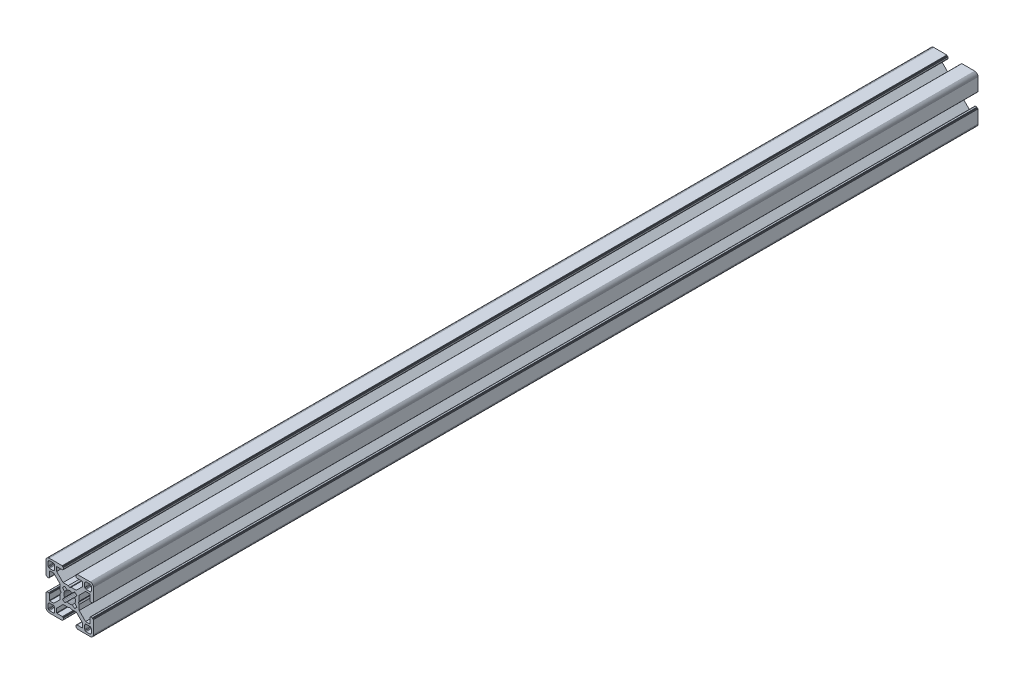
from build123d import *

# Parameters (mm, degrees)
BOSS_EXTRUDE1_DEPTH = 560


with BuildPart() as part:
    # Sketch1 → Boss-Extrude1 (new body)
    with BuildSketch(Plane.XY):
        Polygon((28.34729664, 29.969613999), (28.000000864, 29.999999329), (19.750000909, 29.999999329), (19.715268165, 29.996961355), (19.681595266, 29.987938702), (19.649999216, 29.973205179), (19.621443003, 29.953207821), (19.596790895, 29.928557575), (19.576793537, 29.899999499), (19.562061876, 29.868405312), (19.55303736, 29.834728688), (19.549999386, 29.799999669), (19.549999386, 29.699999839), (19.546961412, 29.665268958), (19.537936896, 29.631596059), (19.523203373, 29.599998146), (19.503207877, 29.571441934), (19.478557631, 29.546789825), (19.449999556, 29.526794329), (19.418403506, 29.512060806), (19.384728745, 29.503038153), (19.349999726, 29.500000179), (19.249999896, 29.500000179), (19.215267517, 29.496958527), (19.181592755, 29.487935874), (19.149996706, 29.47320235), (19.12143863, 29.453206855), (19.096788384, 29.428554746), (19.076791026, 29.399996671), (19.062057503, 29.368402484), (19.05303485, 29.334725859), (19.049996876, 29.299998703), (19.049996876, 28.39999837), (19.059110798, 28.29580945), (19.08618062, 28.194785165), (19.13038119, 28.099997016), (19.190369539, 28.014324653), (19.264324002, 27.94037019), (19.349996366, 27.88038184), (19.444784515, 27.836181271), (19.545806937, 27.809111449), (19.650010894, 27.799984574), (23.050010706, 27.799984574), (23.084741588, 27.7969466), (23.118414487, 27.787923946), (23.150012399, 27.773190423), (23.178568612, 27.753193065), (23.203220721, 27.728542819), (23.223218079, 27.699984744), (23.237949739, 27.668386831), (23.246974255, 27.634713932), (23.25001142, 27.59998608), (23.25001142, 25.049987618), (19.204474482, 20.999982084), (15.900007876, 20.999982084), (15.000008474, 20.48483404), (14.10000814, 20.999982084), (10.795543398, 20.999982084), (7.997342887, 23.801274731), (6.750011387, 25.049984589), (6.750011387, 27.599983051), (6.753049362, 27.634713932), (6.762072946, 27.668386831), (6.776805538, 27.699984744), (6.796801965, 27.728542819), (6.821454073, 27.753193065), (6.850011218, 27.773190423), (6.881607267, 27.787923946), (6.915282029, 27.7969466), (6.950011048, 27.799984574), (10.350011791, 27.799984574), (10.45420071, 27.809098497), (10.555223133, 27.836168318), (10.650011282, 27.880368888), (10.735683645, 27.940357238), (10.809638108, 28.014311701), (10.869626458, 28.099984064), (10.913827027, 28.194772213), (10.940895918, 28.295796498), (10.950010772, 28.399985417), (10.950010772, 29.299985751), (10.946974575, 29.334739239), (10.93795065, 29.368415522), (10.923215933, 29.400009153), (10.903218427, 29.428566473), (10.878566319, 29.45321765), (10.849999264, 29.473204166), (10.818403214, 29.487937689), (10.784728453, 29.496960342), (10.749999434, 29.500000179), (10.649999604, 29.500000179), (10.615270585, 29.503038153), (10.581595823, 29.512060806), (10.549999774, 29.526794329), (10.521441698, 29.546789825), (10.496791452, 29.571441934), (10.476795025, 29.599998146), (10.462061502, 29.631596059), (10.453037918, 29.665268958), (10.449999943, 29.699999839), (10.449999943, 29.799999669), (10.446961969, 29.834728688), (10.437938385, 29.868405312), (10.423205793, 29.899999499), (10.403208435, 29.928557575), (10.378557257, 29.953207821), (10.350000113, 29.973205179), (10.318404064, 29.987938702), (10.284729302, 29.996961355), (10.250000283, 29.999999329), (1.999999397, 29.999999329), (1.652702689, 29.969613999), (1.315958682, 29.879383743), (0.999999233, 29.732050374), (0.714424066, 29.532089829), (0.467910431, 29.285576195), (0.267948955, 28.999999166), (0.120614655, 28.684040532), (0.030384399, 28.34729664), (0, 28.000000864), (0, 19.750000909), (0.003037974, 19.715268165), (0.012061559, 19.681595266), (0.026795082, 19.649999216), (0.046790577, 19.621441141), (0.071442686, 19.596789032), (0.09999983, 19.576793537), (0.13159588, 19.562060013), (0.165270641, 19.55303736), (0.19999966, 19.549999386), (0.299999461, 19.549999386), (0.334728509, 19.546959549), (0.368403242, 19.537936896), (0.399999321, 19.523203373), (0.428556465, 19.503207877), (0.453208573, 19.478555769), (0.473204069, 19.449997693), (0.487937592, 19.418403506), (0.496961176, 19.384728745), (0.499999151, 19.349999726), (0.499999151, 19.249998033), (0.503038056, 19.215269014), (0.512060709, 19.181594253), (0.526794232, 19.150000066), (0.546790194, 19.121441524), (0.571441837, 19.096789882), (0.60000029, 19.076794925), (0.631595686, 19.062061999), (0.665270619, 19.053039982), (0.700000626, 19.050000801), (1.60000096, 19.050000801), (1.704189879, 19.059116587), (1.805213233, 19.086186409), (1.90000045, 19.130385115), (1.985673745, 19.190375328), (2.059627277, 19.264327928), (2.119616325, 19.350002154), (2.163816196, 19.444788441), (2.190886018, 19.545812726), (2.200000872, 19.650001645), (2.200000872, 23.050001457), (2.203039777, 23.084732338), (2.212062431, 23.118405237), (2.226795954, 23.15000315), (2.246792381, 23.178559362), (2.271443558, 23.203211471), (2.300000702, 23.223206967), (2.331596752, 23.23794049), (2.365271513, 23.246965006), (2.400001464, 23.250001117), (4.950000857, 23.250001117), (7.997332093, 20.202670812), (8.995535423, 19.204467788), (8.995535423, 15.900001182), (9.515148227, 15.00000178), (8.995535423, 14.100002378), (8.995535423, 10.795536704), (4.950000857, 6.750002138), (2.400001464, 6.750002138), (2.365271513, 6.753040112), (2.331596752, 6.762063697), (2.300000702, 6.77679722), (2.271443558, 6.796793647), (2.246792381, 6.821444824), (2.226795954, 6.850001968), (2.212062431, 6.881598018), (2.203039777, 6.915272779), (2.200000872, 6.950002729), (2.200000872, 10.350002542), (2.190896812, 10.454174265), (2.16382699, 10.555197618), (2.119627119, 10.649984836), (2.059638071, 10.735658131), (1.985684539, 10.809611663), (1.900011244, 10.869600944), (1.805224027, 10.913800582), (1.704200673, 10.940870404), (1.600011754, 10.949986189), (0.70001142, 10.949986189), (0.665281355, 10.946948596), (0.631606253, 10.937926283), (0.600010578, 10.923193954), (0.571451747, 10.903199537), (0.546799638, 10.87854836), (0.526794232, 10.850000195), (0.512060709, 10.818404146), (0.503038056, 10.784730315), (0.499999151, 10.750000365), (0.499999151, 10.650000535), (0.496961176, 10.615270585), (0.487937592, 10.581596754), (0.473204069, 10.550000705), (0.453208573, 10.521443561), (0.428556465, 10.496791452), (0.399999321, 10.476795956), (0.368403242, 10.462062433), (0.334728509, 10.453038849), (0.299999461, 10.449999943), (0.19999966, 10.449999943), (0.165270641, 10.446961969), (0.13159588, 10.437939316), (0.09999983, 10.423205793), (0.071442686, 10.403209366), (0.046790577, 10.378558189), (0.026795082, 10.350000113), (0.012061559, 10.318404064), (0.003037974, 10.284729302), (0, 10.250000283), (0, 1.999999397), (0.030384399, 1.652702689), (0.120614655, 1.315958682), (0.267948955, 0.999999233), (0.467910431, 0.714424066), (0.714424066, 0.467910431), (0.999999233, 0.267948955), (1.315958682, 0.120614655), (1.652702689, 0.030384399), (1.999999397, 0), (10.250000283, 0), (10.284729302, 0.003037974), (10.318404064, 0.012061559), (10.350000113, 0.026795082), (10.378557257, 0.046790577), (10.403208435, 0.071442686), (10.423205793, 0.09999983), (10.437938385, 0.13159588), (10.446961969, 0.165270641), (10.449999943, 0.19999966), (10.449999943, 0.300000422), (10.453037918, 0.334729441), (10.462061502, 0.368404202), (10.476795025, 0.400000252), (10.496791452, 0.428557396), (10.521441698, 0.453208573), (10.549999774, 0.473205), (10.581595823, 0.487938523), (10.615270585, 0.496961176), (10.649999604, 0.500000082), (10.749999434, 0.500000082), (10.784728453, 0.503038056), (10.818403214, 0.512060709), (10.849999264, 0.526794232), (10.878547894, 0.546800104), (10.903198606, 0.571451747), (10.923194493, 0.6000102), (10.93792742, 0.631606528), (10.946949437, 0.66528146), (10.950010772, 0.699984975), (10.950010772, 1.599985308), (10.940895918, 1.704174228), (10.913827027, 1.805197581), (10.869626458, 1.89998573), (10.809638108, 1.985658094), (10.735683645, 2.059612557), (10.650011282, 2.119600674), (10.555223133, 2.163801476), (10.45420071, 2.190870367), (10.350011791, 2.199985221), (6.950011048, 2.199985221), (6.915282029, 2.203024126), (6.881607267, 2.212046779), (6.850011218, 2.226780302), (6.821454073, 2.246776729), (6.796801965, 2.271427907), (6.776805538, 2.299985982), (6.762072946, 2.331582032), (6.753049362, 2.365256793), (6.750011387, 2.399985812), (6.750011387, 4.949985206), (9.787457566, 7.990785077), (10.795545277, 8.999985833), (14.100010019, 8.999985833), (15.000010353, 9.515133877), (15.900009756, 8.999985833), (19.204476361, 8.999985833), (20.21256413, 7.990786065), (23.25001142, 4.949988235), (23.25001142, 2.399988841), (23.246974255, 2.365256793), (23.237949739, 2.331582032), (23.223218079, 2.299985982), (23.203220721, 2.271427907), (23.178568612, 2.246776729), (23.150012399, 2.226780302), (23.118414487, 2.212046779), (23.084741588, 2.203024126), (23.050010706, 2.199985221), (19.650010894, 2.199985221), (19.545806937, 2.190883319), (19.444784515, 2.163814428), (19.349996366, 2.119613626), (19.264324002, 2.059625509), (19.190369539, 1.985671046), (19.13038119, 1.899998682), (19.08618062, 1.805210533), (19.059110798, 1.70418718), (19.049996876, 1.599998261), (19.049996876, 0.699997927), (19.053035506, 0.665268966), (19.062058795, 0.631594374), (19.076792915, 0.599998603), (19.096790813, 0.571440905), (19.121441524, 0.546790194), (19.149999978, 0.526794306), (19.181596306, 0.51206138), (19.215271238, 0.503039363), (19.249999896, 0.500000082), (19.349999726, 0.500000082), (19.384728745, 0.496961176), (19.418403506, 0.487938523), (19.449999556, 0.473205), (19.478557631, 0.453208573), (19.503207877, 0.428557396), (19.523203373, 0.400000252), (19.537936896, 0.368404202), (19.546961412, 0.334729441), (19.549999386, 0.300000422), (19.549999386, 0.19999966), (19.55303736, 0.165270641), (19.562061876, 0.13159588), (19.576793537, 0.09999983), (19.596789964, 0.071441755), (19.621442072, 0.046789646), (19.649998285, 0.02679415), (19.681594335, 0.012060627), (19.715267234, 0.003037043), (19.750000909, 0), (28.000000864, 0), (28.34729664, 0.030384399), (28.684040532, 0.120614655), (28.999999166, 0.267948955), (29.285576195, 0.467910431), (29.532089829, 0.714424066), (29.732050374, 0.999999233), (29.879383743, 1.315958682), (29.969613999, 1.652702689), (29.999999329, 1.999999397), (29.999999329, 10.250000283), (29.996974806, 10.284715361), (29.987951516, 10.318389952), (29.973217396, 10.349985723), (29.953219499, 10.378543421), (29.928568787, 10.403194133), (29.899999499, 10.423205793), (29.868405312, 10.437939316), (29.834728688, 10.446961969), (29.799999669, 10.449999943), (29.699999839, 10.449999943), (29.664909937, 10.453400043), (29.631233313, 10.462423628), (29.599637263, 10.477157151), (29.57108105, 10.497152646), (29.546427079, 10.521804755), (29.526433446, 10.550361899), (29.511699923, 10.581957949), (29.502675407, 10.615631779), (29.499637433, 10.650361729), (29.499637433, 10.750361559), (29.49697202, 10.784715548), (29.487949367, 10.818389378), (29.473215844, 10.849985428), (29.453220348, 10.878542572), (29.428568239, 10.90319468), (29.400010164, 10.923190176), (29.368415977, 10.937923699), (29.334741215, 10.946947284), (29.300012197, 10.949986189), (28.400011863, 10.949986189), (28.29581215, 10.9408876), (28.194787865, 10.913817778), (28.099999716, 10.86961814), (28.014327352, 10.809628859), (27.940374752, 10.735675327), (27.880384539, 10.650002032), (27.836185833, 10.555214814), (27.809114148, 10.454191461), (27.800000225, 10.350002542), (27.800000225, 6.950002729), (27.796962251, 6.915272779), (27.787939598, 6.881598018), (27.773206075, 6.850001968), (27.753208716, 6.821444824), (27.728558471, 6.796793647), (27.700000395, 6.77679722), (27.668404345, 6.762063697), (27.634729584, 6.753040112), (27.599998702, 6.750002138), (25.05000024, 6.750002138), (23.809199132, 7.99080223), (21.004464477, 10.795534588), (21.004464477, 14.100000262), (20.484851673, 14.999999665), (21.004464477, 15.899999067), (21.004464477, 19.204465672), (25.05000024, 23.250001117), (27.599998702, 23.250001117), (27.634729584, 23.246965006), (27.668404345, 23.23794049), (27.700000395, 23.223206967), (27.728558471, 23.203211471), (27.753208716, 23.178559362), (27.773206075, 23.15000315), (27.787939598, 23.118405237), (27.796962251, 23.084732338), (27.800000225, 23.050001457), (27.800000225, 19.650001645), (27.809114148, 19.545812726), (27.836185833, 19.444788441), (27.880384539, 19.350002154), (27.940370508, 19.264323684), (28.014323108, 19.190371084), (28.099995472, 19.130380872), (28.194783621, 19.086182165), (28.295807906, 19.059112343), (28.400001069, 19.050000801), (29.300001402, 19.050000801), (29.334730421, 19.053040638), (29.368405183, 19.062063291), (29.39999937, 19.076796814), (29.42819671, 19.097149726), (29.452848353, 19.1218023), (29.472843309, 19.150360754), (29.487576235, 19.181955219), (29.496598252, 19.215630151), (29.499637433, 19.250359227), (29.499637433, 19.35036092), (29.502675407, 19.385089939), (29.511699923, 19.4187647), (29.526433446, 19.450358887), (29.546427079, 19.478916963), (29.57108105, 19.503569071), (29.599637263, 19.523564567), (29.631233313, 19.53829809), (29.664909937, 19.547320743), (29.699999839, 19.549999386), (29.799999669, 19.549999386), (29.834728688, 19.55303736), (29.868405312, 19.562060013), (29.899999499, 19.576793537), (29.928557575, 19.596789032), (29.953207821, 19.621441141), (29.973205179, 19.649999216), (29.987938702, 19.681595266), (29.996961355, 19.715268165), (29.999999329, 19.750000909), (29.999999329, 28.000000864), (29.969613999, 28.34729664), (29.879383743, 28.684040532), (29.732050374, 28.999999166), (29.532089829, 29.285576195), (29.285576195, 29.532089829), (28.999999166, 29.732050374), (28.684040532, 29.879383743), align=None)
        Polygon((1.299998723, 25.499999523), (1.299998723, 27.699999511), (1.312309876, 27.856435627), (1.348942518, 28.009016067), (1.408992335, 28.153989464), (1.490981318, 28.287785128), (1.592892222, 28.407108039), (1.71221327, 28.50901708), (1.846008119, 28.591006994), (1.9909814, 28.651056811), (2.143563703, 28.687689453), (2.299998887, 28.699999675), (4.499998875, 28.699999675), (4.656434059, 28.687689453), (4.809016362, 28.651056811), (4.953989759, 28.591006994), (5.087784491, 28.50901708), (5.207106471, 28.407108039), (5.309016444, 28.287785128), (5.391005427, 28.153989464), (5.451056175, 28.009016067), (5.487687886, 27.856435627), (5.499999039, 27.699999511), (5.499999039, 25.499999523), (5.487687886, 25.34356527), (5.451056175, 25.190982968), (5.391005427, 25.04600957), (5.309016444, 24.912213907), (5.207106471, 24.792892858), (5.087784491, 24.690981954), (4.953989759, 24.60899204), (4.809016362, 24.548944086), (4.656434059, 24.512309581), (4.499998875, 24.499999359), (2.299998887, 24.499999359), (2.143563703, 24.512309581), (1.9909814, 24.548944086), (1.846008119, 24.60899204), (1.71221327, 24.690981954), (1.592892222, 24.792892858), (1.490981318, 24.912213907), (1.408992335, 25.04600957), (1.348942518, 25.190982968), (1.312309876, 25.34356527), align=None, mode=Mode.SUBTRACT)
        Polygon((25.34356527, 28.687689453), (25.499999523, 28.699999675), (27.699999511, 28.699999675), (27.856435627, 28.687689453), (28.009017929, 28.651056811), (28.153991327, 28.591006994), (28.28778699, 28.50901708), (28.407108039, 28.407108039), (28.50901708, 28.287785128), (28.591006994, 28.153989464), (28.651056811, 28.009016067), (28.687689453, 27.856435627), (28.700001538, 27.699999511), (28.700001538, 25.499999523), (28.687689453, 25.34356527), (28.651056811, 25.190982968), (28.591006994, 25.04600957), (28.50901708, 24.912213907), (28.407108039, 24.792892858), (28.28778699, 24.690981954), (28.153991327, 24.60899204), (28.009017929, 24.548944086), (27.856435627, 24.512309581), (27.699999511, 24.499999359), (25.499999523, 24.499999359), (25.34356527, 24.512309581), (25.190982968, 24.548944086), (25.04600957, 24.60899204), (24.912215769, 24.690981954), (24.792892858, 24.792892858), (24.690981954, 24.912213907), (24.608993903, 25.04600957), (24.548944086, 25.190982968), (24.512311444, 25.34356527), (24.500001222, 25.499999523), (24.500001222, 27.699999511), (24.512311444, 27.856435627), (24.548944086, 28.009016067), (24.608993903, 28.153989464), (24.690981954, 28.287785128), (24.792892858, 28.407108039), (24.912215769, 28.50901708), (25.04600957, 28.591006994), (25.190982968, 28.651056811), align=None, mode=Mode.SUBTRACT)
        Polygon((14.999999665, 18.649999052), (15.550030395, 18.608318642), (16.087498516, 18.484227359), (16.600128263, 18.280562013), (18.13592948, 19.518401474), (18.644984812, 19.11874488), (19.103571773, 18.662061542), (19.505336881, 18.154669553), (18.280562013, 16.600130126), (18.484227359, 16.087498516), (18.608318642, 15.550030395), (18.649999052, 14.999999665), (18.608318642, 14.449968934), (18.484227359, 13.912500814), (18.280562013, 13.399870135), (19.505336881, 11.845329776), (19.103571773, 11.337937787), (18.644984812, 10.881252587), (18.13592948, 10.481598787), (16.600128263, 11.719437316), (16.087498516, 11.515771039), (15.550030395, 11.391680688), (14.999999665, 11.349999346), (14.449968934, 11.391680688), (13.912500814, 11.515771039), (13.399870135, 11.719437316), (11.864069849, 10.481598787), (11.355013587, 10.881252587), (10.896427557, 11.337937787), (10.494662449, 11.845329776), (11.719438247, 13.399870135), (11.515771039, 13.912500814), (11.391680688, 14.449968934), (11.349999346, 14.999999665), (11.391680688, 15.550030395), (11.515771039, 16.087498516), (11.719438247, 16.600130126), (10.494662449, 18.154669553), (10.896427557, 18.662061542), (11.355013587, 19.11874488), (11.864069849, 19.518401474), (13.399870135, 18.280562013), (13.912500814, 18.484227359), (14.449968934, 18.608318642), align=None, mode=Mode.SUBTRACT)
        Polygon((4.499998875, 1.299999771), (2.299998887, 1.299999771), (2.143563703, 1.312310807), (1.9909814, 1.348942518), (1.846008119, 1.408992335), (1.71221327, 1.490982249), (1.592892222, 1.592892222), (1.490981318, 1.712214202), (1.408992335, 1.846008934), (1.348942518, 1.990982331), (1.312309876, 2.143564634), (1.299998723, 2.299998887), (1.299998723, 4.499999806), (1.312309876, 4.656434059), (1.348942518, 4.809017293), (1.408992335, 4.95399069), (1.490981318, 5.087785423), (1.592892222, 5.207106471), (1.71221327, 5.309017375), (1.846008119, 5.391006358), (1.9909814, 5.451056175), (2.143563703, 5.487688817), (2.299998887, 5.49999997), (4.499998875, 5.49999997), (4.656434059, 5.487688817), (4.809016362, 5.451056175), (4.953989759, 5.391006358), (5.087784491, 5.309017375), (5.207106471, 5.207106471), (5.309016444, 5.087785423), (5.391005427, 4.95399069), (5.451056175, 4.809017293), (5.487687886, 4.656434059), (5.499999039, 4.499999806), (5.499999039, 2.299998887), (5.487687886, 2.143564634), (5.451056175, 1.990982331), (5.391005427, 1.846008934), (5.309016444, 1.712214202), (5.207106471, 1.592892222), (5.087784491, 1.490982249), (4.953989759, 1.408992335), (4.809016362, 1.348942518), (4.656434059, 1.312310807), align=None, mode=Mode.SUBTRACT)
        Polygon((27.699999511, 1.299999771), (25.499999523, 1.299999771), (25.34356527, 1.312310807), (25.190982968, 1.348942518), (25.04600957, 1.408992335), (24.912215769, 1.490982249), (24.792892858, 1.592892222), (24.690981954, 1.712214202), (24.608993903, 1.846008934), (24.548944086, 1.990982331), (24.512311444, 2.143564634), (24.500001222, 2.299998887), (24.500001222, 4.499999806), (24.512311444, 4.656434059), (24.548944086, 4.809017293), (24.608993903, 4.95399069), (24.690981954, 5.087785423), (24.792892858, 5.207106471), (24.912215769, 5.309017375), (25.04600957, 5.391006358), (25.190982968, 5.451056175), (25.34356527, 5.487688817), (25.499999523, 5.49999997), (27.699999511, 5.49999997), (27.856435627, 5.487688817), (28.009017929, 5.451056175), (28.153991327, 5.391006358), (28.28778699, 5.309017375), (28.407108039, 5.207106471), (28.50901708, 5.087785423), (28.591006994, 4.95399069), (28.651056811, 4.809017293), (28.687689453, 4.656434059), (28.700001538, 4.499999806), (28.700001538, 2.299998887), (28.687689453, 2.143564634), (28.651056811, 1.990982331), (28.591006994, 1.846008934), (28.50901708, 1.712214202), (28.407108039, 1.592892222), (28.28778699, 1.490982249), (28.153991327, 1.408992335), (28.009017929, 1.348942518), (27.856435627, 1.312310807), align=None, mode=Mode.SUBTRACT)
    extrude(amount=-BOSS_EXTRUDE1_DEPTH)


solid = part.part
